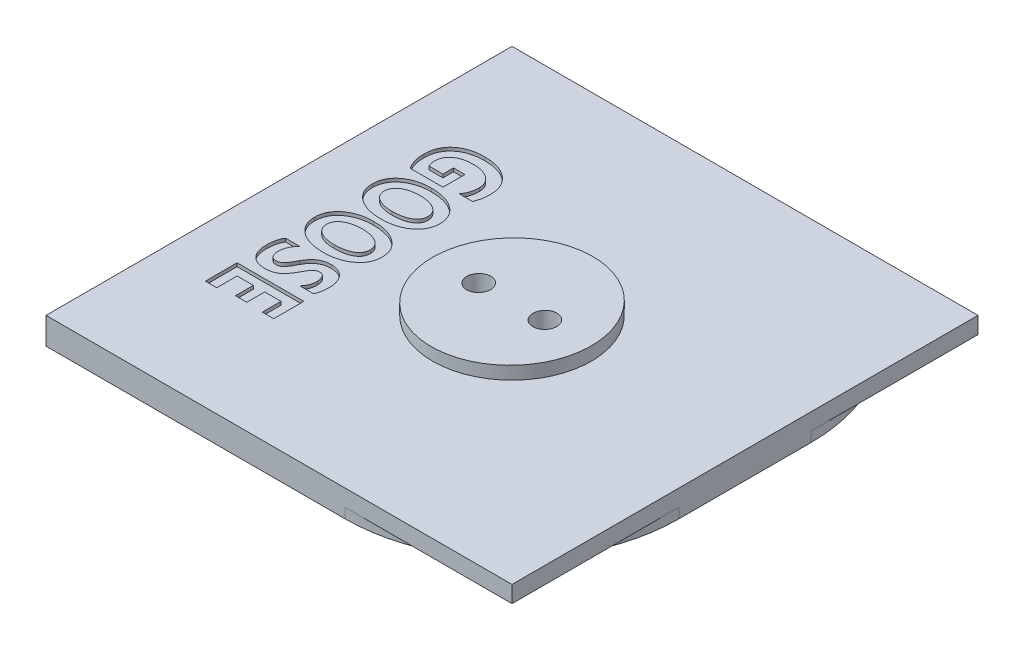
from build123d import *

# Parameters (mm, degrees)
SKETCH1_W           = 69.85
SKETCH1_H           = 69.85
BOSS_EXTRUDE1_DEPTH = 4
SKETCH2_R           = 11.90625
BOSS_EXTRUDE2_DEPTH = 2
CUT_EXTRUDE2_DEPTH  = 70.85
CUT_EXTRUDE1_REACH  = 8.401
SKETCH3_R           = 1.7859375
CUT_EXTRUDE3_DEPTH  = 0.5
CUT_EXTRUDE4_DEPTH  = 1.5


with BuildPart() as part:
    # Sketch1 → Boss-Extrude1 (new body)
    with BuildSketch(Plane(origin=(0, 0, 0), x_dir=(1, 0, 0), z_dir=(0, 1, 0))):
        with Locations((34.925, 34.925)):
            Rectangle(SKETCH1_W, SKETCH1_H)
    extrude(amount=BOSS_EXTRUDE1_DEPTH)

    # Sketch2 → Boss-Extrude2 (add)
    with BuildSketch(Plane(origin=(0, 4, 0), x_dir=(1, 0, 0), z_dir=(0, 1, 0))):
        with Locations((34.925, 34.925)):
            Circle(SKETCH2_R)
    extrude(amount=BOSS_EXTRUDE2_DEPTH)

    # Sketch4 → Cut-Extrude2 (cut, through all)
    with BuildSketch(Plane(origin=(0, 0, 0), x_dir=(-1, 0, 0), z_dir=(0, 0, -1))):
        Polygon((-46.83125, 6), (-23.01875, 6), (-23.01875, 5.584351266), align=None)
    extrude(amount=CUT_EXTRUDE2_DEPTH, mode=Mode.SUBTRACT)

    # Cut-Extrude1: up to this face of the body (flat: up to its plane)
    cut_extrude1_end = Plane(part.part.faces().sort_by_distance((34.925, 0, -34.925))[0])
    # Sketch3 → Cut-Extrude1 (cut, up to the picked face)
    with BuildSketch(Plane(origin=(0.007132626, 5.182681991, 0), x_dir=(0.999847695, 0.017452406, 0), z_dir=(-0.017452406, 0.999847695, 0)), mode=Mode.PRIVATE) as cut_extrude1_sk1:
        with Locations((29.930971067, 34.925)):
            Circle(SKETCH3_R)
    cut_extrude1_tool1 = split(extrude(cut_extrude1_sk1.sketch, amount=-CUT_EXTRUDE1_REACH, mode=Mode.PRIVATE), bisect_by=cut_extrude1_end, keep=Keep.BOTH, mode=Mode.PRIVATE)
    add(cut_extrude1_tool1.solids().sort_by_distance((29.933545, 5.705049, -34.925))[0], mode=Mode.SUBTRACT)
    # Sketch3 → Cut-Extrude1 (cut, up to the picked face)
    with BuildSketch(Plane(origin=(0.007132626, 5.182681991, 0), x_dir=(0.999847695, 0.017452406, 0), z_dir=(-0.017452406, 0.999847695, 0)), mode=Mode.PRIVATE) as cut_extrude1_sk2:
        with Locations((39.852846067, 34.925)):
            Circle(SKETCH3_R)
    cut_extrude1_tool2 = split(extrude(cut_extrude1_sk2.sketch, amount=-CUT_EXTRUDE1_REACH, mode=Mode.PRIVATE), bisect_by=cut_extrude1_end, keep=Keep.BOTH, mode=Mode.PRIVATE)
    add(cut_extrude1_tool2.solids().sort_by_distance((39.853909, 5.87821, -34.925))[0], mode=Mode.SUBTRACT)

    # Sketch6 → Cut-Extrude3 (cut)
    with BuildSketch(Plane(origin=(0, 4, 0), x_dir=(1, 0, 0), z_dir=(0, 1, 0))):
        with BuildLine():
            add(Edge.make_bspline(
                [(8.210746951, 46.388414634), (8.144274713, 46.489009703), (8.011200203, 46.690396625), (7.841032576, 47.012884002), (7.698639266, 47.353240837), (7.580207721, 47.709835183), (7.488636108, 48.083234812), (7.424176489, 48.473706042), (7.385953722, 48.881296199), (7.380712454, 49.158912255), (7.37804878, 49.3)],
                knots=[0, 0, 0, 0, 0.000361561, 0.000723829, 0.001091884, 0.001467285, 0.001849947, 0.002244028, 0.002653579, 0.003076808, 0.003076808, 0.003076808, 0.003076808], degree=3))
            add(Edge.make_bspline(
                [(7.37804878, 49.3), (7.381808754, 49.456488516), (7.389161953, 49.762525597), (7.454413518, 50.208498087), (7.55528239, 50.631029508), (7.703518672, 51.026808603), (7.890305447, 51.398097163), (8.122427688, 51.741041446), (8.391620784, 52.062184966), (8.705379376, 52.352601314), (9.053983543, 52.612895229), (9.434039299, 52.841707584), (9.845263352, 53.033239566), (10.28622121, 53.192605453), (10.758494505, 53.313963145), (11.26100657, 53.39727702), (11.793078545, 53.453204269), (12.158131513, 53.458741135), (12.345655488, 53.461585366)],
                knots=[0, 0, 0, 0, 0.000469218, 0.000917628, 0.001349279, 0.00177012, 0.002182573, 0.002593209, 0.003009679, 0.003437057, 0.003872652, 0.004312836, 0.004765468, 0.005231394, 0.005717592, 0.006226018, 0.006758424, 0.007320805, 0.007320805, 0.007320805, 0.007320805], degree=3))
            add(Edge.make_bspline(
                [(12.345655488, 53.461585366), (12.536357719, 53.458103208), (12.909758722, 53.451285031), (13.455645242, 53.392791786), (13.974907069, 53.299202649), (14.465803229, 53.162466388), (14.931549548, 52.992677866), (15.367421121, 52.778871941), (15.778366641, 52.530916376), (16.157343495, 52.244444224), (16.500335529, 51.926722307), (16.80235491, 51.58341647), (17.054408646, 51.212268256), (17.265531017, 50.819446334), (17.424878767, 50.399400847), (17.539088757, 49.95661113), (17.60967499, 49.489635013), (17.617796553, 49.17004457), (17.62195122, 49.006554878)],
                knots=[0, 0, 0, 0, 0.000571964, 0.001119923, 0.001645026, 0.002153081, 0.002646852, 0.003130054, 0.003607172, 0.00408469, 0.00455256, 0.005007684, 0.005453231, 0.00589564, 0.006342586, 0.006797359, 0.007265446, 0.00775569, 0.00775569, 0.00775569, 0.00775569], degree=3))
            add(Edge.make_bspline(
                [(17.62195122, 49.006554878), (17.620405082, 48.900446847), (17.617365309, 48.691833966), (17.595825574, 48.384088133), (17.561926351, 48.08709295), (17.514602672, 47.800049122), (17.452036053, 47.523101535), (17.372918903, 47.257231798), (17.284972742, 46.99965161), (17.212217044, 46.835720432), (17.176067073, 46.754268293)],
                knots=[0, 0, 0, 0, 0.000318308, 0.000625806, 0.000925035, 0.001214801, 0.001498161, 0.001776134, 0.00204672, 0.002313937, 0.002313937, 0.002313937, 0.002313937], degree=3))
            Line((17.176067073, 46.754268293), (15.182926829, 46.754268293))
            add(Edge.make_bspline(
                [(15.182926829, 46.754268293), (15.241573527, 46.833293826), (15.358291723, 46.990569821), (15.506885605, 47.244281145), (15.63386436, 47.510506838), (15.735607243, 47.790341472), (15.816892855, 48.082624461), (15.873125571, 48.388057029), (15.908323164, 48.706566466), (15.912509469, 48.923255468), (15.914634146, 49.033231707)],
                knots=[0, 0, 0, 0, 0.000295049, 0.000587205, 0.000880408, 0.001178817, 0.001479304, 0.001789495, 0.002109555, 0.002439402, 0.002439402, 0.002439402, 0.002439402], degree=3))
            add(Edge.make_bspline(
                [(15.914634146, 49.033231707), (15.911682042, 49.128042132), (15.905903483, 49.313627555), (15.861195101, 49.584980778), (15.78680917, 49.842345893), (15.681139798, 50.086305871), (15.544946936, 50.315751088), (15.3792424, 50.531302602), (15.183245811, 50.731540038), (14.960261651, 50.917552078), (14.714198963, 51.086930916), (14.444997259, 51.231606471), (14.15851898, 51.355067801), (13.853955311, 51.459562909), (13.528915654, 51.536498736), (13.185500713, 51.590569064), (12.823413574, 51.626378353), (12.575673199, 51.630303162), (12.448551829, 51.632317073)],
                knots=[0, 0, 0, 0, 0.000284327, 0.000556551, 0.000822481, 0.001086197, 0.001351881, 0.001620953, 0.001899891, 0.002190707, 0.002490911, 0.002794452, 0.003105957, 0.003425926, 0.003759147, 0.004106557, 0.004468324, 0.004849593, 0.004849593, 0.004849593, 0.004849593], degree=3))
            add(Edge.make_bspline(
                [(12.448551829, 51.632317073), (12.319549339, 51.630743019), (12.068781924, 51.62768322), (11.704077879, 51.596735091), (11.361405332, 51.546097873), (11.040616977, 51.473313979), (10.740436623, 51.383102722), (10.462252183, 51.270215197), (10.206447121, 51.1367831), (9.972483353, 50.984724458), (9.765357339, 50.812797401), (9.582059575, 50.627858348), (9.428163778, 50.426220841), (9.303471957, 50.208726082), (9.205732081, 49.976378466), (9.135065316, 49.728969261), (9.092265748, 49.466634068), (9.087694978, 49.286823922), (9.085365854, 49.195198171)],
                knots=[0, 0, 0, 0, 0.000386931, 0.000752154, 0.001097095, 0.001425304, 0.001738135, 0.002036427, 0.002324503, 0.002602495, 0.002871844, 0.003130555, 0.003382087, 0.003630488, 0.003880696, 0.004136415, 0.004400811, 0.004675525, 0.004675525, 0.004675525, 0.004675525], degree=3))
            add(Edge.make_bspline(
                [(9.085365854, 49.195198171), (9.087999983, 49.088287378), (9.093059639, 48.88293235), (9.139311658, 48.590707285), (9.212384429, 48.326654756), (9.29120166, 48.170938519), (9.329268293, 48.095731707)],
                knots=[0, 0, 0, 0, 0.000320485, 0.000615589, 0.000885712, 0.001138043, 0.001138043, 0.001138043, 0.001138043], degree=3))
            Line((9.329268293, 48.095731707), (11.402439024, 48.095731707))
            Line((11.402439024, 48.095731707), (11.402439024, 49.681097561))
            Line((11.402439024, 49.681097561), (13.109756098, 49.681097561))
            Line((13.109756098, 49.681097561), (13.109756098, 46.388414634))
            Line((13.109756098, 46.388414634), (8.210746951, 46.388414634))
        make_face()
        with BuildLine():
            add(Edge.make_bspline(
                [(12.372332317, 45.412804878), (12.561732286, 45.409664284), (12.932365492, 45.403518514), (13.474839556, 45.351013526), (13.990806584, 45.266163524), (14.479787963, 45.146686602), (14.941394312, 44.992045512), (15.375888198, 44.803152073), (15.783581343, 44.579432253), (16.161785635, 44.323550537), (16.503719041, 44.039322137), (16.804593499, 43.732011315), (17.055311036, 43.399135346), (17.264471982, 43.046072718), (17.424158197, 42.668839076), (17.539201735, 42.270456116), (17.609526072, 41.850127955), (17.6177528, 41.56208898), (17.62195122, 41.415091463)],
                knots=[0, 0, 0, 0, 0.000568094, 0.001111693, 0.001633271, 0.00213563, 0.002620097, 0.003091989, 0.003555057, 0.004013271, 0.004459741, 0.004886914, 0.00530041, 0.005706954, 0.006115035, 0.006525706, 0.006948609, 0.00738937, 0.00738937, 0.00738937, 0.00738937], degree=3))
            add(Edge.make_bspline(
                [(17.62195122, 41.415091463), (17.617441063, 41.27510688), (17.608616579, 41.00121578), (17.542726642, 40.600464482), (17.43225414, 40.221572714), (17.276422151, 39.8627129), (17.074259472, 39.526631204), (16.831213805, 39.208986467), (16.539419441, 38.916937686), (16.209079549, 38.646257147), (15.845004655, 38.401327656), (15.451522909, 38.190094826), (15.034915449, 38.007273157), (14.59101181, 37.86172057), (14.122713754, 37.747468675), (13.629798374, 37.66570506), (13.111326414, 37.61824963), (12.757339147, 37.611420826), (12.576219512, 37.607926829)],
                knots=[0, 0, 0, 0, 0.00041983, 0.000821432, 0.001214573, 0.001601142, 0.001991656, 0.002388409, 0.002798023, 0.003227181, 0.003667942, 0.004112154, 0.004565279, 0.005031065, 0.005511705, 0.006010102, 0.006528682, 0.007072017, 0.007072017, 0.007072017, 0.007072017], degree=3))
            add(Edge.make_bspline(
                [(12.576219512, 37.607926829), (12.38743924, 37.610973441), (12.018675967, 37.61692469), (11.479665903, 37.670523808), (10.967519251, 37.751519468), (10.48331696, 37.873527694), (10.02466363, 38.024058552), (9.594304747, 38.212486267), (9.189363315, 38.430760601), (8.817971546, 38.686159349), (8.479874069, 38.966387639), (8.185518019, 39.272087431), (7.93390375, 39.598085042), (7.731869668, 39.947451531), (7.570903985, 40.316417658), (7.459491178, 40.707306959), (7.390836414, 41.119225657), (7.382371652, 41.400844573), (7.37804878, 41.544664634)],
                knots=[0, 0, 0, 0, 0.00056619, 0.001105995, 0.001623502, 0.002120312, 0.002602367, 0.003070004, 0.0035279, 0.003980316, 0.004419955, 0.004843111, 0.005250903, 0.005652233, 0.006050809, 0.006455459, 0.006868651, 0.007299898, 0.007299898, 0.007299898, 0.007299898], degree=3))
            add(Edge.make_bspline(
                [(7.37804878, 41.544664634), (7.381571465, 41.684692223), (7.388498842, 41.960057155), (7.458130336, 42.362009138), (7.566258529, 42.744755177), (7.718986256, 43.106975365), (7.91866586, 43.447515008), (8.159610575, 43.76907129), (8.44608771, 44.069459327), (8.773492806, 44.34581543), (9.13432037, 44.595942619), (9.522406067, 44.816023282), (9.936392267, 45.001814602), (10.375831729, 45.150997066), (10.839358862, 45.270291654), (11.328237827, 45.352835085), (11.842188281, 45.403005049), (12.193099922, 45.409491728), (12.372332317, 45.412804878)],
                knots=[0, 0, 0, 0, 0.000419731, 0.000825403, 0.001219844, 0.001610915, 0.002001135, 0.002401287, 0.002813728, 0.003243625, 0.003684465, 0.004129036, 0.004580218, 0.005043612, 0.005519634, 0.006014591, 0.006529556, 0.007067177, 0.007067177, 0.007067177, 0.007067177], degree=3))
        make_face()
        with BuildLine():
            add(Edge.make_bspline(
                [(12.486661585, 43.583536585), (12.369125312, 43.581395486), (12.138873676, 43.577201107), (11.80145716, 43.553560811), (11.481102797, 43.508670661), (11.176313546, 43.451050865), (10.888631379, 43.372586402), (10.617040318, 43.27770531), (10.362318787, 43.164580339), (10.125072193, 43.036510058), (9.910484528, 42.893296835), (9.722292963, 42.735580945), (9.563861185, 42.563723562), (9.432149392, 42.380132577), (9.331898818, 42.181890005), (9.258863703, 41.971933945), (9.216590028, 41.747683445), (9.210452077, 41.594382108), (9.207317073, 41.516082317)],
                knots=[0, 0, 0, 0, 0.000352644, 0.000690824, 0.001013932, 0.001322609, 0.001620755, 0.001907618, 0.002184865, 0.002456014, 0.002715504, 0.002957531, 0.003190819, 0.003414987, 0.003633147, 0.003854905, 0.004079881, 0.004314752, 0.004314752, 0.004314752, 0.004314752], degree=3))
            add(Edge.make_bspline(
                [(9.207317073, 41.516082317), (9.209628523, 41.436493302), (9.21417426, 41.279972133), (9.257381592, 41.052580496), (9.326243261, 40.838623449), (9.422087765, 40.637924622), (9.54783571, 40.45234143), (9.699090961, 40.278834522), (9.881369811, 40.123069881), (10.086056141, 39.978136747), (10.316421663, 39.851505711), (10.565192283, 39.738969391), (10.833945328, 39.645743085), (11.120868224, 39.570512609), (11.426002008, 39.508386289), (11.750350248, 39.468906278), (12.092976038, 39.44004979), (12.327803715, 39.438164524), (12.448551829, 39.437195122)],
                knots=[0, 0, 0, 0, 0.000238559, 0.000469155, 0.00069151, 0.000911393, 0.001133887, 0.001362077, 0.001599767, 0.001851407, 0.002113292, 0.002387059, 0.002669695, 0.002965506, 0.003276422, 0.003603056, 0.00394518, 0.004307303, 0.004307303, 0.004307303, 0.004307303], degree=3))
            add(Edge.make_bspline(
                [(12.448551829, 39.437195122), (12.574357416, 39.43843158), (12.819241859, 39.440838385), (13.176080587, 39.465998295), (13.512722352, 39.507250251), (13.828859409, 39.566428607), (14.125337708, 39.639749794), (14.40129138, 39.731366826), (14.656671226, 39.839984728), (14.892555871, 39.9629347), (15.10287313, 40.103383725), (15.288939171, 40.255955477), (15.44456006, 40.424796254), (15.571590077, 40.607812315), (15.672129767, 40.80357757), (15.74294062, 41.01413208), (15.785735294, 41.238041969), (15.790340759, 41.392035331), (15.792682927, 41.47035061)],
                knots=[0, 0, 0, 0, 0.000377364, 0.00073455, 0.001072526, 0.001394305, 0.001698861, 0.001988094, 0.00226557, 0.002530659, 0.002784861, 0.003022978, 0.003250881, 0.003471301, 0.003689461, 0.003908799, 0.004135648, 0.004370402, 0.004370402, 0.004370402, 0.004370402], degree=3))
            add(Edge.make_bspline(
                [(15.792682927, 41.47035061), (15.789585778, 41.550559104), (15.783544072, 41.707024305), (15.74107241, 41.93561855), (15.668119294, 42.150355769), (15.566117352, 42.352388446), (15.435110187, 42.540792896), (15.274468487, 42.71497533), (15.087390526, 42.87792427), (14.870513201, 43.022635401), (14.634140397, 43.155970861), (14.377159745, 43.269848852), (14.103834471, 43.366964297), (13.813601798, 43.44732333), (13.505765106, 43.507415151), (13.181257513, 43.550860104), (12.83963447, 43.577967575), (12.606123171, 43.581651787), (12.486661585, 43.583536585)],
                knots=[0, 0, 0, 0, 0.000240575, 0.000469297, 0.000694661, 0.00091878, 0.001146069, 0.001380762, 0.001627954, 0.001888512, 0.002161502, 0.002441265, 0.002730561, 0.003031048, 0.003343833, 0.003670717, 0.004012841, 0.0043712, 0.0043712, 0.0043712, 0.0043712], degree=3))
        make_face(mode=Mode.SUBTRACT)
        with BuildLine():
            add(Edge.make_bspline(
                [(12.372332317, 36.754268293), (12.561732286, 36.751127698), (12.932365492, 36.744981929), (13.474839556, 36.692476941), (13.990806584, 36.607626938), (14.479787963, 36.488150017), (14.941394312, 36.333508926), (15.375888198, 36.144615488), (15.783581343, 35.920895668), (16.161785635, 35.665013952), (16.503719041, 35.380785552), (16.804593499, 35.07347473), (17.055311036, 34.740598761), (17.264471982, 34.387536133), (17.424158197, 34.010302491), (17.539201735, 33.611919531), (17.609526072, 33.19159137), (17.6177528, 32.903552395), (17.62195122, 32.756554878)],
                knots=[0, 0, 0, 0, 0.000568094, 0.001111693, 0.001633271, 0.00213563, 0.002620097, 0.003091989, 0.003555057, 0.004013271, 0.004459741, 0.004886914, 0.00530041, 0.005706954, 0.006115035, 0.006525706, 0.006948609, 0.00738937, 0.00738937, 0.00738937, 0.00738937], degree=3))
            add(Edge.make_bspline(
                [(17.62195122, 32.756554878), (17.617441063, 32.616570294), (17.608616579, 32.342679195), (17.542726642, 31.941927896), (17.43225414, 31.563036129), (17.276422151, 31.204176314), (17.074259472, 30.868094618), (16.831213805, 30.550449881), (16.539419441, 30.258401101), (16.209079549, 29.987720562), (15.845004655, 29.74279107), (15.451522909, 29.53155824), (15.034915449, 29.348736572), (14.59101181, 29.203183985), (14.122713754, 29.088932089), (13.629798374, 29.007168474), (13.111326414, 28.959713045), (12.757339147, 28.952884241), (12.576219512, 28.949390244)],
                knots=[0, 0, 0, 0, 0.00041983, 0.000821432, 0.001214573, 0.001601142, 0.001991656, 0.002388409, 0.002798023, 0.003227181, 0.003667942, 0.004112154, 0.004565279, 0.005031065, 0.005511705, 0.006010102, 0.006528682, 0.007072017, 0.007072017, 0.007072017, 0.007072017], degree=3))
            add(Edge.make_bspline(
                [(12.576219512, 28.949390244), (12.38743924, 28.952436856), (12.018675967, 28.958388105), (11.479665903, 29.011987223), (10.967519251, 29.092982883), (10.48331696, 29.214991108), (10.02466363, 29.365521967), (9.594304747, 29.553949681), (9.189363315, 29.772224016), (8.817971546, 30.027622764), (8.479874069, 30.307851053), (8.185518019, 30.613550846), (7.93390375, 30.939548456), (7.731869668, 31.288914946), (7.570903985, 31.657881072), (7.459491178, 32.048770373), (7.390836414, 32.460689071), (7.382371652, 32.742307988), (7.37804878, 32.886128049)],
                knots=[0, 0, 0, 0, 0.00056619, 0.001105995, 0.001623502, 0.002120312, 0.002602367, 0.003070004, 0.0035279, 0.003980316, 0.004419955, 0.004843111, 0.005250903, 0.005652233, 0.006050809, 0.006455459, 0.006868651, 0.007299898, 0.007299898, 0.007299898, 0.007299898], degree=3))
            add(Edge.make_bspline(
                [(7.37804878, 32.886128049), (7.381571465, 33.026155638), (7.388498842, 33.30152057), (7.458130336, 33.703472552), (7.566258529, 34.086218591), (7.718986256, 34.44843878), (7.91866586, 34.788978422), (8.159610575, 35.110534704), (8.44608771, 35.410922742), (8.773492806, 35.687278845), (9.13432037, 35.937406033), (9.522406067, 36.157486697), (9.936392267, 36.343278016), (10.375831729, 36.492460481), (10.839358862, 36.611755068), (11.328237827, 36.6942985), (11.842188281, 36.744468464), (12.193099922, 36.750955143), (12.372332317, 36.754268293)],
                knots=[0, 0, 0, 0, 0.000419731, 0.000825403, 0.001219844, 0.001610915, 0.002001135, 0.002401287, 0.002813728, 0.003243625, 0.003684465, 0.004129036, 0.004580218, 0.005043612, 0.005519634, 0.006014591, 0.006529556, 0.007067177, 0.007067177, 0.007067177, 0.007067177], degree=3))
        make_face()
        with BuildLine():
            add(Edge.make_bspline(
                [(12.486661585, 34.925), (12.369125312, 34.9228589), (12.138873676, 34.918664521), (11.80145716, 34.895024226), (11.481102797, 34.850134076), (11.176313546, 34.79251428), (10.888631379, 34.714049817), (10.617040318, 34.619168725), (10.362318787, 34.506043753), (10.125072193, 34.377973472), (9.910484528, 34.23476025), (9.722292963, 34.07704436), (9.563861185, 33.905186977), (9.432149392, 33.721595992), (9.331898818, 33.523353419), (9.258863703, 33.313397359), (9.216590028, 33.08914686), (9.210452077, 32.935845522), (9.207317073, 32.857545732)],
                knots=[0, 0, 0, 0, 0.000352644, 0.000690824, 0.001013932, 0.001322609, 0.001620755, 0.001907618, 0.002184865, 0.002456014, 0.002715504, 0.002957531, 0.003190819, 0.003414987, 0.003633147, 0.003854905, 0.004079881, 0.004314752, 0.004314752, 0.004314752, 0.004314752], degree=3))
            add(Edge.make_bspline(
                [(9.207317073, 32.857545732), (9.209628523, 32.777956717), (9.21417426, 32.621435548), (9.257381592, 32.39404391), (9.326243261, 32.180086864), (9.422087765, 31.979388037), (9.54783571, 31.793804845), (9.699090961, 31.620297936), (9.881369811, 31.464533296), (10.086056141, 31.319600162), (10.316421663, 31.192969125), (10.565192283, 31.080432805), (10.833945328, 30.9872065), (11.120868224, 30.911976024), (11.426002008, 30.849849704), (11.750350248, 30.810369692), (12.092976038, 30.781513205), (12.327803715, 30.779627938), (12.448551829, 30.778658537)],
                knots=[0, 0, 0, 0, 0.000238559, 0.000469155, 0.00069151, 0.000911393, 0.001133887, 0.001362077, 0.001599767, 0.001851407, 0.002113292, 0.002387059, 0.002669695, 0.002965506, 0.003276422, 0.003603056, 0.00394518, 0.004307303, 0.004307303, 0.004307303, 0.004307303], degree=3))
            add(Edge.make_bspline(
                [(12.448551829, 30.778658537), (12.574357416, 30.779894995), (12.819241859, 30.782301799), (13.176080587, 30.80746171), (13.512722352, 30.848713665), (13.828859409, 30.907892022), (14.125337708, 30.981213209), (14.40129138, 31.072830241), (14.656671226, 31.181448142), (14.892555871, 31.304398115), (15.10287313, 31.444847139), (15.288939171, 31.597418892), (15.44456006, 31.766259669), (15.571590077, 31.949275729), (15.672129767, 32.145040985), (15.74294062, 32.355595495), (15.785735294, 32.579505383), (15.790340759, 32.733498745), (15.792682927, 32.811814024)],
                knots=[0, 0, 0, 0, 0.000377364, 0.00073455, 0.001072526, 0.001394305, 0.001698861, 0.001988094, 0.00226557, 0.002530659, 0.002784861, 0.003022978, 0.003250881, 0.003471301, 0.003689461, 0.003908799, 0.004135648, 0.004370402, 0.004370402, 0.004370402, 0.004370402], degree=3))
            add(Edge.make_bspline(
                [(15.792682927, 32.811814024), (15.789585778, 32.892022518), (15.783544072, 33.04848772), (15.74107241, 33.277081965), (15.668119294, 33.491819184), (15.566117352, 33.69385186), (15.435110187, 33.882256311), (15.274468487, 34.056438744), (15.087390526, 34.219387685), (14.870513201, 34.364098815), (14.634140397, 34.497434275), (14.377159745, 34.611312267), (14.103834471, 34.708427712), (13.813601798, 34.788786744), (13.505765106, 34.848878566), (13.181257513, 34.892323519), (12.83963447, 34.919430989), (12.606123171, 34.923115201), (12.486661585, 34.925)],
                knots=[0, 0, 0, 0, 0.000240575, 0.000469297, 0.000694661, 0.00091878, 0.001146069, 0.001380762, 0.001627954, 0.001888512, 0.002161502, 0.002441265, 0.002730561, 0.003031048, 0.003343833, 0.003670717, 0.004012841, 0.0043712, 0.0043712, 0.0043712, 0.0043712], degree=3))
        make_face(mode=Mode.SUBTRACT)
        with BuildLine():
            add(Edge.make_bspline(
                [(10.06097561, 27.973780488), (9.983145547, 27.891977285), (9.830309704, 27.73133934), (9.632492804, 27.470633528), (9.463381892, 27.203211357), (9.324811357, 26.927077004), (9.217704216, 26.642139657), (9.141425585, 26.349046012), (9.093853854, 26.047618124), (9.08821494, 25.843619834), (9.085365854, 25.74054878)],
                knots=[0, 0, 0, 0, 0.000338518, 0.000664752, 0.000979843, 0.001286621, 0.001589929, 0.001891267, 0.002193904, 0.002502969, 0.002502969, 0.002502969, 0.002502969], degree=3))
            add(Edge.make_bspline(
                [(9.085365854, 25.74054878), (9.0856863, 25.683336574), (9.086310653, 25.571865221), (9.102965507, 25.410399347), (9.12462095, 25.259271005), (9.157067784, 25.119673048), (9.198458963, 24.99114791), (9.251032082, 24.874512826), (9.308862332, 24.766122855), (9.402258563, 24.642290481), (9.534344119, 24.51096071), (9.720891494, 24.397130652), (9.929214864, 24.327946245), (10.075692695, 24.31953931), (10.150533537, 24.315243902)],
                knots=[0, 0, 0, 0, 0.000171536, 0.000334218, 0.000486479, 0.000629301, 0.000763675, 0.000890787, 0.001012753, 0.001131277, 0.001354959, 0.001567051, 0.001781569, 0.00200568, 0.00200568, 0.00200568, 0.00200568], degree=3))
            add(Edge.make_bspline(
                [(10.150533537, 24.315243902), (10.21760376, 24.318302854), (10.35137784, 24.324404049), (10.547770946, 24.381861978), (10.737296395, 24.471068735), (10.893747216, 24.571917884), (11.015295577, 24.68594369), (11.118921535, 24.799093241), (11.228068111, 24.94301287), (11.346031261, 25.114868014), (11.471294931, 25.315460356), (11.605032964, 25.544696562), (11.744615287, 25.803784706), (11.840255949, 25.986258547), (11.890243902, 26.081631098)],
                knots=[0, 0, 0, 0, 0.00020081, 0.000400523, 0.000608535, 0.000828386, 0.000955155, 0.001107558, 0.001288218, 0.001496466, 0.001732785, 0.001997504, 0.002292528, 0.002615569, 0.002615569, 0.002615569, 0.002615569], degree=3))
            add(Edge.make_bspline(
                [(11.890243902, 26.081631098), (11.931348606, 26.158314244), (12.01234913, 26.309425295), (12.145468391, 26.523737919), (12.285239748, 26.723671701), (12.432458753, 26.90804968), (12.583581881, 27.080722789), (12.745451094, 27.235349554), (12.912666523, 27.377131146), (13.088288616, 27.502666036), (13.269663196, 27.613732489), (13.458261322, 27.709857706), (13.65377821, 27.791526084), (13.856374312, 27.858271639), (14.065842313, 27.910558476), (14.282036063, 27.945155778), (14.505281346, 27.969838497), (14.656306367, 27.972450203), (14.733231707, 27.973780488)],
                knots=[0, 0, 0, 0, 0.000260961, 0.000514248, 0.000756365, 0.000992353, 0.001221804, 0.001444159, 0.001663249, 0.001878999, 0.002091091, 0.002300729, 0.002513411, 0.002726118, 0.002940094, 0.003160316, 0.003382532, 0.003613222, 0.003613222, 0.003613222, 0.003613222], degree=3))
            add(Edge.make_bspline(
                [(14.733231707, 27.973780488), (14.844517391, 27.971378181), (15.061491464, 27.966694394), (15.377224123, 27.925676845), (15.674646125, 27.860330511), (15.95143696, 27.764218709), (16.210439075, 27.643778586), (16.448566322, 27.49462911), (16.668803232, 27.31913796), (16.867580278, 27.117693787), (17.044659792, 26.893984505), (17.200338059, 26.65237239), (17.331406478, 26.392975258), (17.439295266, 26.116210875), (17.520281403, 25.821575973), (17.578831928, 25.509939566), (17.616296245, 25.1812469), (17.620037867, 24.956226957), (17.62195122, 24.841158537)],
                knots=[0, 0, 0, 0, 0.000333727, 0.000650669, 0.000953455, 0.001245717, 0.001527864, 0.001808618, 0.002086565, 0.002370866, 0.002655658, 0.002941081, 0.003231672, 0.003526081, 0.003830751, 0.004146912, 0.00447665, 0.004821732, 0.004821732, 0.004821732, 0.004821732], degree=3))
            add(Edge.make_bspline(
                [(17.62195122, 24.841158537), (17.621070444, 24.744578699), (17.619341844, 24.555032144), (17.599364009, 24.276566383), (17.569132483, 24.009523962), (17.528282951, 23.754108684), (17.472208076, 23.511347656), (17.406155181, 23.27996729), (17.326406457, 23.060294105), (17.262727089, 22.920676142), (17.23132622, 22.851829268)],
                knots=[0, 0, 0, 0, 0.000289691, 0.000568544, 0.000837048, 0.001095802, 0.001344028, 0.001584044, 0.001817332, 0.002044277, 0.002044277, 0.002044277, 0.002044277], degree=3))
            Line((17.23132622, 22.851829268), (15.182926829, 22.851829268))
            add(Edge.make_bspline(
                [(15.182926829, 22.851829268), (15.241353304, 22.920064548), (15.356533103, 23.054581064), (15.505747627, 23.271635111), (15.631816919, 23.496904724), (15.735730854, 23.730844884), (15.815724238, 23.973487606), (15.873010159, 24.22480172), (15.908211065, 24.484466391), (15.912478028, 24.660662356), (15.914634146, 24.749695122)],
                knots=[0, 0, 0, 0, 0.000269349, 0.000530984, 0.000788613, 0.001042836, 0.001297724, 0.001553804, 0.001815211, 0.002082224, 0.002082224, 0.002082224, 0.002082224], degree=3))
            add(Edge.make_bspline(
                [(15.914634146, 24.749695122), (15.911585705, 24.850268644), (15.905752953, 25.042701553), (15.85527155, 25.315748118), (15.766959744, 25.55697134), (15.645062357, 25.763716045), (15.496019198, 25.934722658), (15.316170515, 26.056705983), (15.112638443, 26.13354977), (14.96766084, 26.140795436), (14.893292683, 26.144512195)],
                knots=[0, 0, 0, 0, 0.000301555, 0.000576982, 0.000828997, 0.00106821, 0.001293549, 0.001503369, 0.001714354, 0.00193657, 0.00193657, 0.00193657, 0.00193657], degree=3))
            add(Edge.make_bspline(
                [(14.893292683, 26.144512195), (14.832027515, 26.140953218), (14.710186392, 26.1338753), (14.530747654, 26.08435411), (14.360286583, 26.000236692), (14.222416662, 25.904933337), (14.115355285, 25.801205358), (14.026153567, 25.699968113), (13.930843178, 25.574650211), (13.828351669, 25.425562357), (13.717777339, 25.252417258), (13.602807364, 25.053659864), (13.478399414, 24.833226495), (13.396416015, 24.676887418), (13.353658537, 24.59535061)],
                knots=[0, 0, 0, 0, 0.000183729, 0.000365391, 0.000553736, 0.000751989, 0.000865201, 0.001000182, 0.001156443, 0.001337214, 0.001542839, 0.001772583, 0.002025955, 0.002302139, 0.002302139, 0.002302139, 0.002302139], degree=3))
            add(Edge.make_bspline(
                [(13.353658537, 24.59535061), (13.30128518, 24.498243402), (13.199361733, 24.3092637), (13.034990477, 24.04381217), (12.871512325, 23.799605454), (12.703523741, 23.580583257), (12.534719965, 23.383555929), (12.362383366, 23.210587965), (12.18787088, 23.061848116), (12.009305811, 22.935945815), (11.826910949, 22.828539471), (11.63728503, 22.736017235), (11.437607017, 22.660805425), (11.230669051, 22.595211061), (11.014611072, 22.545802004), (10.790358274, 22.51207408), (10.558088356, 22.490601499), (10.400199694, 22.487532261), (10.320121951, 22.48597561)],
                knots=[0, 0, 0, 0, 0.000330919, 0.000644, 0.000936261, 0.001212188, 0.001471573, 0.001714102, 0.001943932, 0.002158577, 0.002368708, 0.002578355, 0.002790678, 0.003008246, 0.003229192, 0.003454757, 0.00368817, 0.003928382, 0.003928382, 0.003928382, 0.003928382], degree=3))
            add(Edge.make_bspline(
                [(10.320121951, 22.48597561), (10.203776964, 22.488523256), (9.9780551, 22.493465965), (9.6496152, 22.532064284), (9.342319435, 22.595551018), (9.05649224, 22.687799408), (8.791345396, 22.803925325), (8.547516036, 22.94698248), (8.327143352, 23.119162398), (8.125757701, 23.313504383), (7.948601505, 23.533493061), (7.795204509, 23.77603413), (7.664855025, 24.040239435), (7.561451189, 24.327085643), (7.478822658, 24.634262223), (7.420907106, 24.963253782), (7.383625884, 25.314130535), (7.379940505, 25.555616926), (7.37804878, 25.679573171)],
                knots=[0, 0, 0, 0, 0.000348959, 0.000677019, 0.000990569, 0.001288855, 0.001576356, 0.001857401, 0.002134491, 0.002413429, 0.002695248, 0.002979644, 0.003272792, 0.003577224, 0.00389292, 0.004225944, 0.004578418, 0.004950164, 0.004950164, 0.004950164, 0.004950164], degree=3))
            add(Edge.make_bspline(
                [(7.37804878, 25.679573171), (7.380147969, 25.793940335), (7.384246371, 26.017227809), (7.408340013, 26.344430459), (7.452244311, 26.655601987), (7.513383274, 26.950709927), (7.588461891, 27.231042444), (7.684798042, 27.494261458), (7.795468955, 27.743313049), (7.886007998, 27.897682379), (7.930640244, 27.973780488)],
                knots=[0, 0, 0, 0, 0.00034312, 0.000669899, 0.00098357, 0.001285149, 0.001573603, 0.001853288, 0.002125319, 0.002389798, 0.002389798, 0.002389798, 0.002389798], degree=3))
            Line((7.930640244, 27.973780488), (10.06097561, 27.973780488))
        make_face()
        Polygon((7.5, 16.388414634), (7.5, 21.144512195), (17.5, 21.144512195), (17.5, 16.632317073), (15.792682927, 16.632317073), (15.792682927, 19.433384146), (13.353658537, 19.433384146), (13.353658537, 16.754268293), (11.646341463, 16.754268293), (11.646341463, 19.437195122), (9.207317073, 19.437195122), (9.207317073, 16.388414634), align=None)
    extrude(amount=-CUT_EXTRUDE3_DEPTH, mode=Mode.SUBTRACT)

    # Sketch8 → Cut-Extrude4 (cut)
    with BuildSketch(Plane.XZ):
        with BuildLine():
            Line((69.85, 0), (44.85, 0))
            ThreePointArc((44.85, 0), (62.52766953, -7.32233047), (69.85, -25))
            Line((69.85, -25), (69.85, 0))
        make_face()
    cut_extrude4 = extrude(amount=-CUT_EXTRUDE4_DEPTH, mode=Mode.SUBTRACT)

    # Mirror1: Cut-Extrude4 across plane
    add(cut_extrude4.mirror(Plane.XY.offset(-34.925)), mode=Mode.SUBTRACT)


solid = part.part
